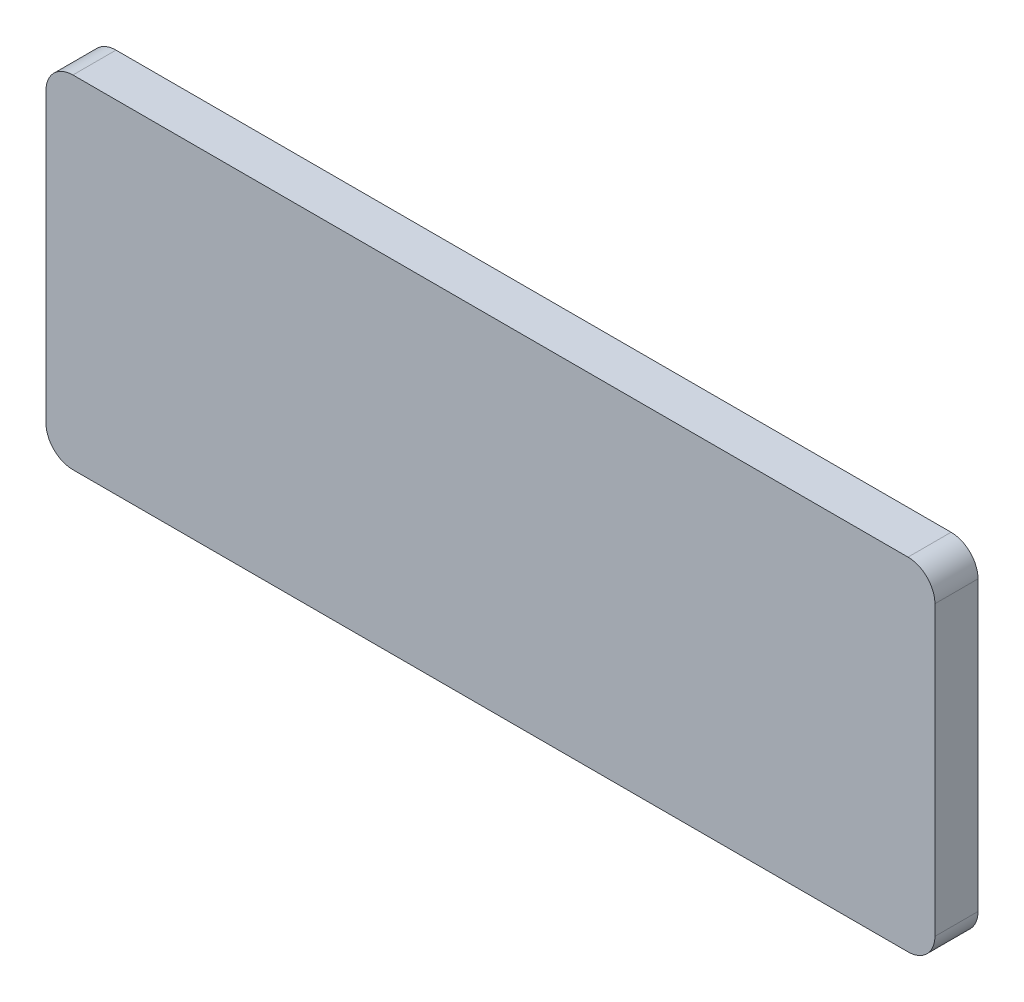
from build123d import *

# Parameters (mm, degrees)
SKETCH_1_W      = 33.02
SKETCH_1_H      = 12.7
EXTRUDE_1_DEPTH = 1.6
FILLET_1_R      = 1


with BuildPart() as part:
    # 草图1 → 凸台-拉伸1 (new body)
    with BuildSketch(Plane.XY):
        Rectangle(SKETCH_1_W, SKETCH_1_H)
    extrude(amount=EXTRUDE_1_DEPTH)

    # 圆角1
    fillet_1_edges = [part.edges().sort_by_distance(p)[0] for p in [
        (-16.51, 6.35, 0.8),
        (16.51, 6.35, 0.8),
        (16.51, -6.35, 0.8),
        (-16.51, -6.35, 0.8),
    ]]
    fillet(fillet_1_edges, radius=FILLET_1_R)


solid = part.part
